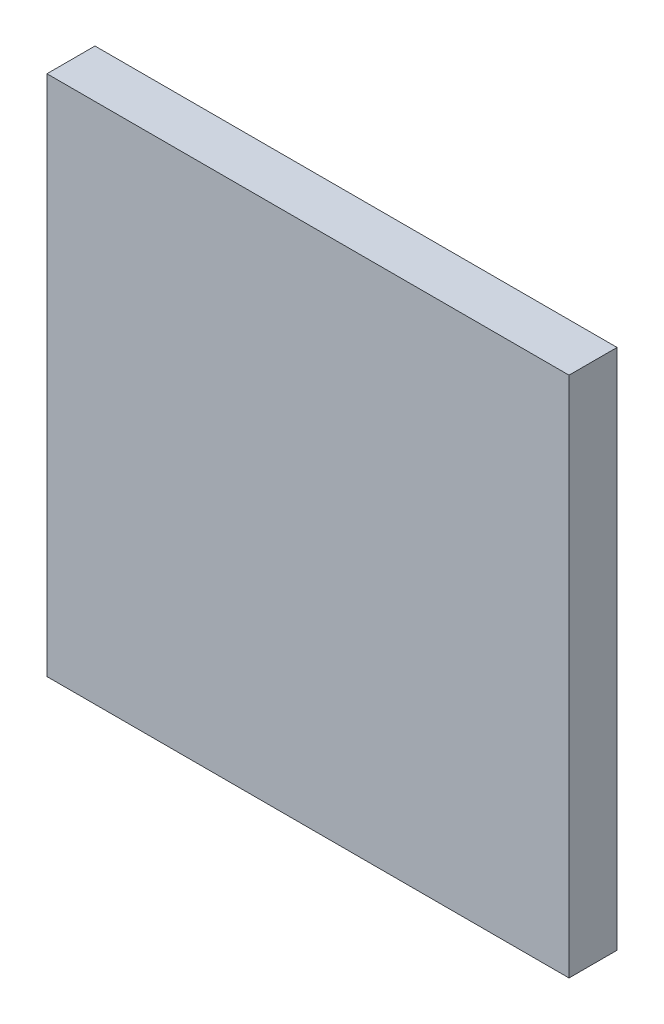
from build123d import *

# Parameters (mm, degrees)
SKETCH_1_W      = 25
SKETCH_1_H      = 25
EXTRUDE_1_DEPTH = 2.3


with BuildPart() as part:
    # 草图1 → 凸台-拉伸1 (new body)
    with BuildSketch(Plane.XY):
        with Locations((101.247935776, 61.563241835)):
            Rectangle(SKETCH_1_W, SKETCH_1_H)
    extrude(amount=EXTRUDE_1_DEPTH)


solid = part.part
